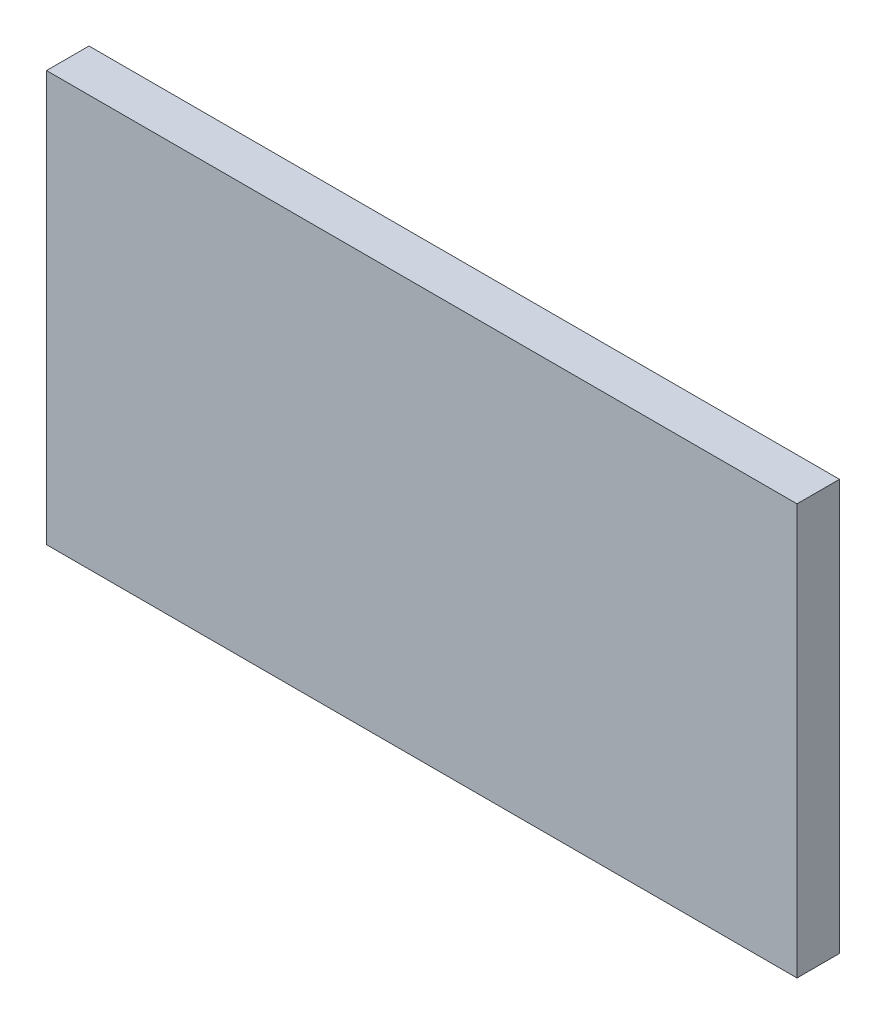
from build123d import *

# Parameters (mm, degrees)
SKETCH1_W           = 13.462
SKETCH1_H           = 7.366
BOSS_EXTRUDE1_DEPTH = 0.762


with BuildPart() as part:
    # Sketch1 → Boss-Extrude1 (new body)
    with BuildSketch(Plane.XY.offset(204.787070427)):
        with Locations((-500.516231154, -471.495739889)):
            Rectangle(SKETCH1_W, SKETCH1_H)
    extrude(amount=BOSS_EXTRUDE1_DEPTH)


solid = part.part
